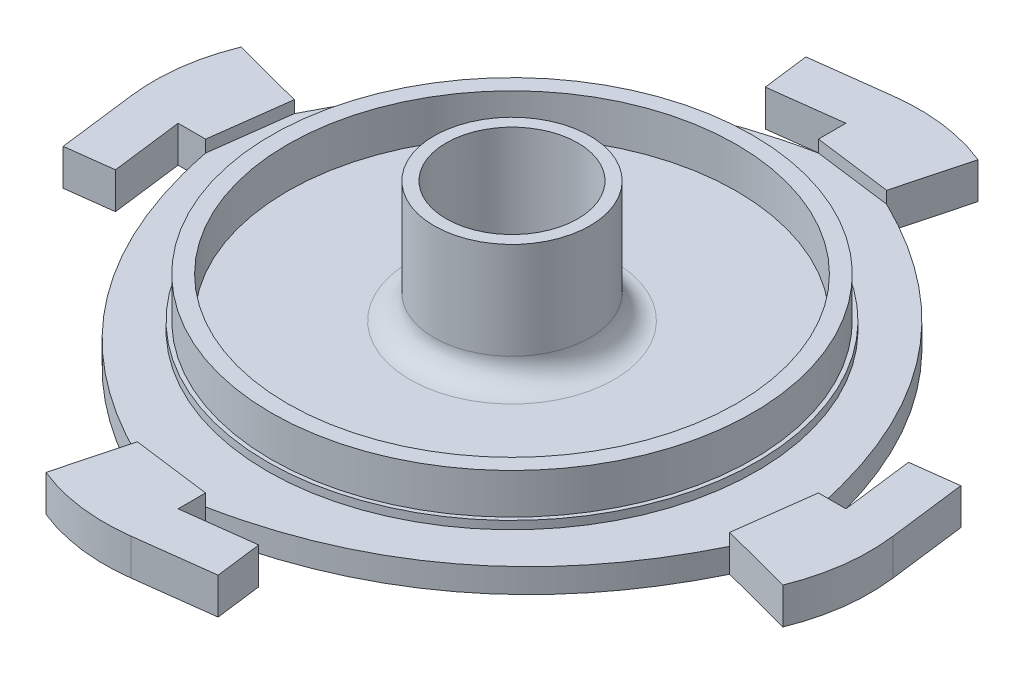
from build123d import *

# Parameters (mm, degrees)
BOSS_EXTRUDE1_DEPTH = 3
BOSS_EXTRUDE2_START = 3
BOSS_EXTRUDE2_DEPTH = 1.5
SKETCH2_R           = 30.3
SKETCH2_R_2         = 29.8
SKETCH2_R_3         = 27.8
BOSS_EXTRUDE3_DEPTH = 1
SKETCH3_R           = 29.8
SKETCH3_R_2         = 27.8
BOSS_EXTRUDE4_DEPTH = 5
SKETCH4_R           = 9.65
SKETCH4_R_2         = 8.15
BOSS_EXTRUDE5_DEPTH = 15
FILLET1_R           = 3
SKETCH5_R           = 8.15
CUT_EXTRUDE1_DEPTH  = 19


with BuildPart() as part:
    # Sketch1 → Boss-Extrude1 (new body)
    with BuildSketch(Plane(origin=(0, 0, 0), x_dir=(1, 0, 0), z_dir=(0, 1, 0))):
        with BuildLine():
            add(Edge.make_bspline(
                [(-9.71796746, -36.684650856), (-32.908122366, -25.325665089), (-37.95, 0)],
                knots=[0, 0, 0, 1, 1, 1], degree=2))
            Line((-37.95, 0), (-36.684650856, 9.71796746))
            add(Edge.make_bspline(
                [(-36.684650856, 9.71796746), (-25.325665089, 32.908122366), (0, 37.95)],
                knots=[0, 0, 0, 1, 1, 1], degree=2))
            Line((0, 37.95), (9.71796746, 36.684650856))
            add(Edge.make_bspline(
                [(9.71796746, 36.684650856), (32.908122366, 25.325665089), (37.95, 0)],
                knots=[0, 0, 0, 1, 1, 1], degree=2))
            Line((37.95, 0), (36.684650856, -9.71796746))
            add(Edge.make_bspline(
                [(36.684650856, -9.71796746), (25.325665089, -32.908122366), (0, -37.95)],
                knots=[0, 0, 0, 1, 1, 1], degree=2))
            Line((0, -37.95), (-9.71796746, -36.684650856))
        make_face()
        with BuildLine():
            Line((-36.684650856, 9.71796746), (-45.626232422, 12.086642005))
            add(Edge.make_bspline(
                [(-45.626232422, 12.086642005), (-47.200054133, 8.194360075), (-47.724535059, 4.165503049), (-47.2, 0)],
                knots=[0, 0, 0, 0, 1, 1, 1, 1], degree=3))
            Line((-47.2, 0), (-45.991859888, -9.594232511))
            Line((-45.991859888, -9.594232511), (-40.237304711, -8.869598317))
            Line((-40.237304711, -8.869598317), (-41.354196291, 0))
            Line((-41.354196291, 0), (-37.95, 0))
            Line((-37.95, 0), (-36.684650856, 9.71796746))
        make_face()
        with BuildLine():
            Line((-9.71796746, -36.684650856), (-12.086642005, -45.626232422))
            add(Edge.make_bspline(
                [(-12.086642005, -45.626232422), (-8.194360105, -47.200054362), (-4.165503019, -47.72453483), (0, -47.2)],
                knots=[0, 0, 0, 0, 1, 1, 1, 1], degree=3))
            Line((0, -47.2), (9.594232575, -45.991860399))
            Line((9.594232575, -45.991860399), (8.869598688, -40.237305183))
            Line((8.869598688, -40.237305183), (0, -41.35419633))
            Line((0, -41.35419633), (0, -37.95))
            Line((0, -37.95), (-9.71796746, -36.684650856))
        make_face()
        with BuildLine():
            add(Edge.make_bspline(
                [(47.2, 0), (47.724535051, -4.165503048), (47.200054142, -8.194360076), (45.626232422, -12.086642005)],
                knots=[0, 0, 0, 0, 1, 1, 1, 1], degree=3))
            Line((45.626232422, -12.086642005), (36.684650856, -9.71796746))
            Line((36.684650856, -9.71796746), (37.95, 0))
            Line((37.95, 0), (41.354196292, 0))
            Line((41.354196292, 0), (40.237304729, 8.869598332))
            Line((40.237304729, 8.869598332), (45.991859908, 9.594232513))
            Line((45.991859908, 9.594232513), (47.2, 0))
        make_face()
        with BuildLine():
            Line((9.71796746, 36.684650856), (12.086642005, 45.626232422))
            add(Edge.make_bspline(
                [(12.086642005, 45.626232422), (8.194360088, 47.200054234), (4.165503036, 47.724534958), (0, 47.2)],
                knots=[0, 0, 0, 0, 1, 1, 1, 1], degree=3))
            Line((0, 47.2), (-9.594232539, 45.991860113))
            Line((-9.594232539, 45.991860113), (-8.869598481, 40.237304919))
            Line((-8.869598481, 40.237304919), (0, 41.354196308))
            Line((0, 41.354196308), (0, 37.95))
            Line((0, 37.95), (9.71796746, 36.684650856))
        make_face()
    extrude(amount=BOSS_EXTRUDE1_DEPTH)

    # Sketch1_3 → Boss-Extrude2 (add)
    with BuildSketch(Plane(origin=(0, 0, 0), x_dir=(1, 0, 0), z_dir=(0, 1, 0)).offset(BOSS_EXTRUDE2_START)):
        with BuildLine():
            Line((-9.71796746, -36.684650856), (-12.086642005, -45.626232422))
            add(Edge.make_bspline(
                [(-12.086642005, -45.626232422), (-8.194360105, -47.200054362), (-4.165503019, -47.72453483), (0, -47.2)],
                knots=[0, 0, 0, 0, 1, 1, 1, 1], degree=3))
            Line((0, -47.2), (9.594232575, -45.991860399))
            Line((9.594232575, -45.991860399), (8.869598688, -40.237305183))
            Line((8.869598688, -40.237305183), (0, -41.35419633))
            Line((0, -41.35419633), (0, -37.95))
            Line((0, -37.95), (-9.71796746, -36.684650856))
        make_face()
        with BuildLine():
            add(Edge.make_bspline(
                [(47.2, 0), (47.724535051, -4.165503048), (47.200054142, -8.194360076), (45.626232422, -12.086642005)],
                knots=[0, 0, 0, 0, 1, 1, 1, 1], degree=3))
            Line((45.626232422, -12.086642005), (36.684650856, -9.71796746))
            Line((36.684650856, -9.71796746), (37.95, 0))
            Line((37.95, 0), (41.354196292, 0))
            Line((41.354196292, 0), (40.237304729, 8.869598332))
            Line((40.237304729, 8.869598332), (45.991859908, 9.594232513))
            Line((45.991859908, 9.594232513), (47.2, 0))
        make_face()
        with BuildLine():
            Line((9.71796746, 36.684650856), (12.086642005, 45.626232422))
            add(Edge.make_bspline(
                [(12.086642005, 45.626232422), (8.194360088, 47.200054234), (4.165503036, 47.724534958), (0, 47.2)],
                knots=[0, 0, 0, 0, 1, 1, 1, 1], degree=3))
            Line((0, 47.2), (-9.594232539, 45.991860113))
            Line((-9.594232539, 45.991860113), (-8.869598481, 40.237304919))
            Line((-8.869598481, 40.237304919), (0, 41.354196308))
            Line((0, 41.354196308), (0, 37.95))
            Line((0, 37.95), (9.71796746, 36.684650856))
        make_face()
        with BuildLine():
            Line((-36.684650856, 9.71796746), (-45.626232422, 12.086642005))
            add(Edge.make_bspline(
                [(-45.626232422, 12.086642005), (-47.200054133, 8.194360075), (-47.724535059, 4.165503049), (-47.2, 0)],
                knots=[0, 0, 0, 0, 1, 1, 1, 1], degree=3))
            Line((-47.2, 0), (-45.991859888, -9.594232511))
            Line((-45.991859888, -9.594232511), (-40.237304711, -8.869598317))
            Line((-40.237304711, -8.869598317), (-41.354196291, 0))
            Line((-41.354196291, 0), (-37.95, 0))
            Line((-37.95, 0), (-36.684650856, 9.71796746))
        make_face()
    extrude(amount=BOSS_EXTRUDE2_DEPTH)

    # Sketch2 → Boss-Extrude3 (add)
    with BuildSketch(Plane(origin=(0, 3, 0), x_dir=(1, 0, 0), z_dir=(0, 1, 0))):
        Circle(SKETCH2_R)
        Circle(SKETCH2_R_2, mode=Mode.SUBTRACT)
        Circle(SKETCH2_R_2)
        Circle(SKETCH2_R_3, mode=Mode.SUBTRACT)
        Circle(SKETCH2_R_3)
    extrude(amount=BOSS_EXTRUDE3_DEPTH)

    # Sketch3 → Boss-Extrude4 (add)
    with BuildSketch(Plane(origin=(0, 4, 0), x_dir=(1, 0, 0), z_dir=(0, 1, 0))):
        Circle(SKETCH3_R)
        Circle(SKETCH3_R_2, mode=Mode.SUBTRACT)
    extrude(amount=BOSS_EXTRUDE4_DEPTH)

    # Sketch4 → Boss-Extrude5 (add)
    with BuildSketch(Plane(origin=(0, 4, 0), x_dir=(1, 0, 0), z_dir=(0, 1, 0))):
        Circle(SKETCH4_R)
        Circle(SKETCH4_R_2, mode=Mode.SUBTRACT)
    extrude(amount=BOSS_EXTRUDE5_DEPTH)

    # Fillet1
    fillet1_edges = [part.edges().sort_by_distance(p)[0] for p in [
        (-9.65, 4, 0),
    ]]
    fillet(fillet1_edges, radius=FILLET1_R)

    # Sketch5 → Cut-Extrude1 (cut)
    with BuildSketch(Plane.XZ):
        Circle(SKETCH5_R)
    extrude(amount=-CUT_EXTRUDE1_DEPTH, mode=Mode.SUBTRACT)


solid = part.part
